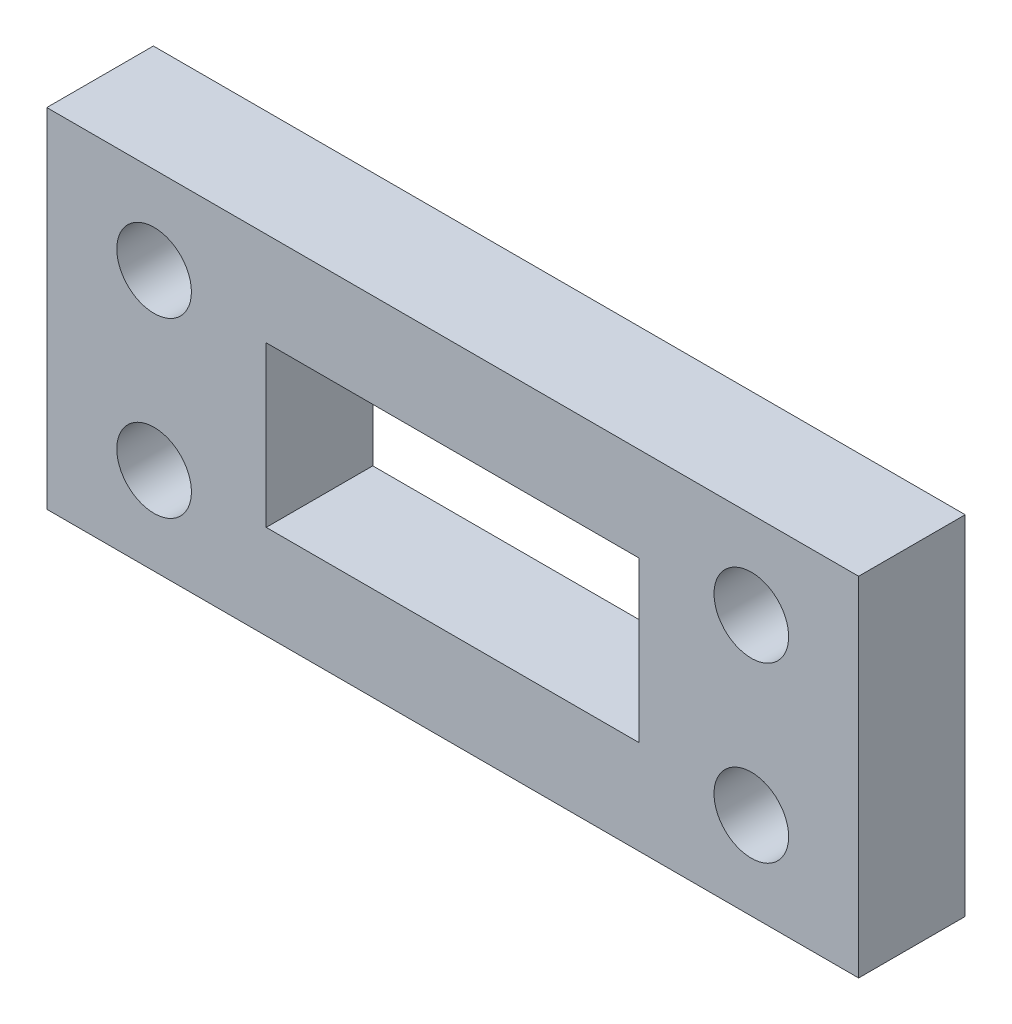
from build123d import *

# Parameters (mm, degrees)
CROQUIS1_W              = 152.350272222
CROQUIS1_H              = 65.29297381
CROQUIS1_R              = 7
CROQUIS1_W_2            = 70
CROQUIS1_H_2            = 30
SALIENTE_EXTRUIR1_DEPTH = 20


with BuildPart() as part:
    # Croquis1 → Saliente-Extruir1 (new body)
    with BuildSketch(Plane.XY):
        Rectangle(CROQUIS1_W, CROQUIS1_H)
        with Locations((-56.038969429, 16.250537634)):
            Circle(CROQUIS1_R, mode=Mode.SUBTRACT)
        with Locations((56.038969429, 16.250537634)):
            Circle(CROQUIS1_R, mode=Mode.SUBTRACT)
        with Locations((56.038969429, -16.250537634)):
            Circle(CROQUIS1_R, mode=Mode.SUBTRACT)
        with Locations((-56.038969429, -16.250537634)):
            Circle(CROQUIS1_R, mode=Mode.SUBTRACT)
        Rectangle(CROQUIS1_W_2, CROQUIS1_H_2, mode=Mode.SUBTRACT)
    extrude(amount=SALIENTE_EXTRUIR1_DEPTH)


solid = part.part
